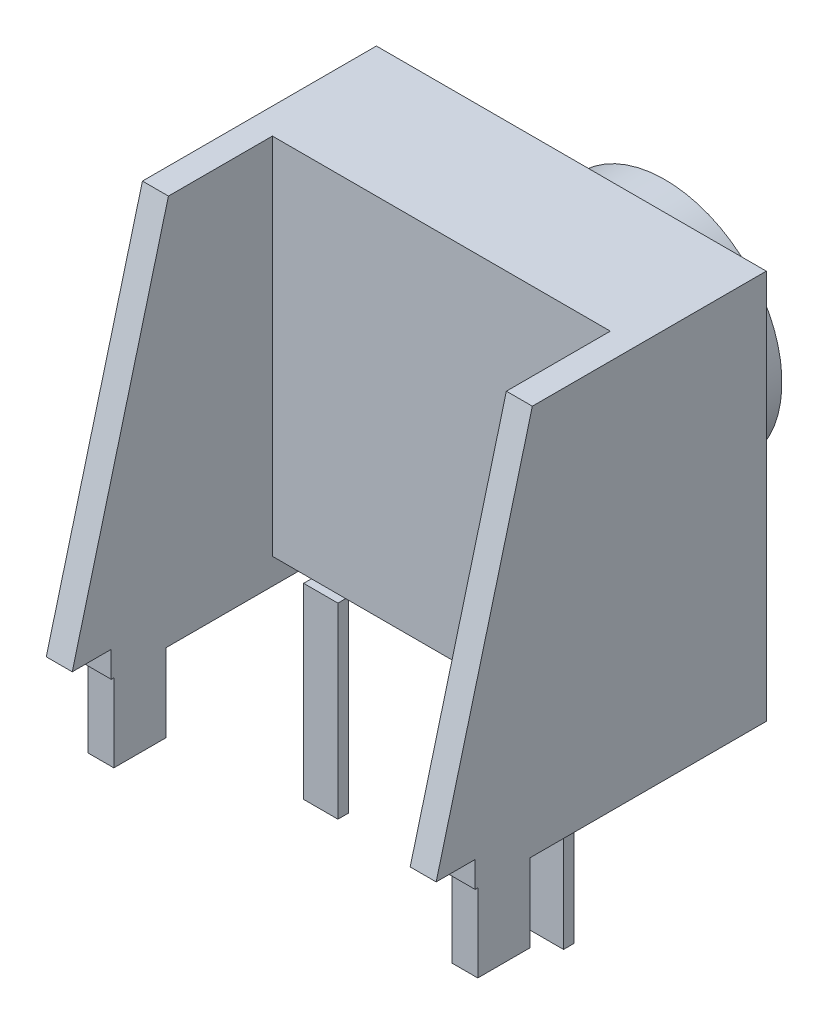
from build123d import *

# Parameters (mm, degrees)
SKETCH_1_W      = 7.5
SKETCH_1_H      = 7
EXTRUDE_1_DEPTH = 2.5
SKETCH_2_R      = 2.25
EXTRUDE_2_DEPTH = 1.8
EXTRUDE_3_DEPTH = 0.5
SKETCH_4_W      = 1
SKETCH_4_H      = 2
EXTRUDE_4_DEPTH = 0.5
SKETCH_5_W      = 0.66
SKETCH_5_H      = 0.2
EXTRUDE_5_DEPTH = 3.6
SKETCH_6_W      = 0.5
SKETCH_6_H      = 0.5
EXTRUDE_6_DEPTH = 5.6


with BuildPart() as part:
    # 草图1 → 凸台-拉伸1 (new body)
    with BuildSketch(Plane.XY):
        Rectangle(SKETCH_1_W, SKETCH_1_H)
    extrude(amount=EXTRUDE_1_DEPTH)

    # 草图2 → 凸台-拉伸2 (add)
    with BuildSketch(Plane(origin=(0, 0, 0), x_dir=(-1, 0, 0), z_dir=(0, 0, -1))):
        Circle(SKETCH_2_R)
    extrude(amount=EXTRUDE_2_DEPTH)

    # 草图3 → 凸台-拉伸3 (add)
    with BuildSketch(Plane(origin=(3.75, 0, 0), x_dir=(0, 0, -1), z_dir=(1, 0, 0))):
        Polygon((0, 3.5), (0, -3.5), (-2.5, -3.5), (-6.35, -3.5), (-4.5, 3.5), align=None)
    extrude_3 = extrude(amount=-EXTRUDE_3_DEPTH)

    # 草图4 → 凸台-拉伸4 (add)
    with BuildSketch(Plane(origin=(3.75, 0, 0), x_dir=(0, 0, -1), z_dir=(1, 0, 0))):
        with Locations((-5.05, -4.5)):
            Rectangle(SKETCH_4_W, SKETCH_4_H)
    extrude_4 = extrude(amount=-EXTRUDE_4_DEPTH)

    # 镜向1: 凸台-拉伸3, 凸台-拉伸4 across plane
    add(extrude_3.mirror(Plane(origin=(0, 0, 0), x_dir=(0, 0, 1), z_dir=(1, 0, 0))))
    add(extrude_4.mirror(Plane(origin=(0, 0, 0), x_dir=(0, 0, 1), z_dir=(1, 0, 0))))

    # 草图5 → 凸台-拉伸5 (add)
    with BuildSketch(Plane.XZ.offset(3.5)):
        with Locations((-2.169711975, 2.55)):
            Rectangle(SKETCH_5_W, SKETCH_5_H)
        with Locations((2.169711975, 2.55)):
            Rectangle(SKETCH_5_W, SKETCH_5_H)
    extrude(amount=EXTRUDE_5_DEPTH)

    # 草图6 → 凸台-拉伸6 (add)
    with BuildSketch(Plane(origin=(0, 0, 0), x_dir=(-1, 0, 0), z_dir=(0, 0, -1))):
        with Locations((-3.5, -3.75)):
            Rectangle(SKETCH_6_W, SKETCH_6_H)
        with Locations((3.5, -3.75)):
            Rectangle(SKETCH_6_W, SKETCH_6_H)
    extrude(amount=-EXTRUDE_6_DEPTH)


solid = part.part
